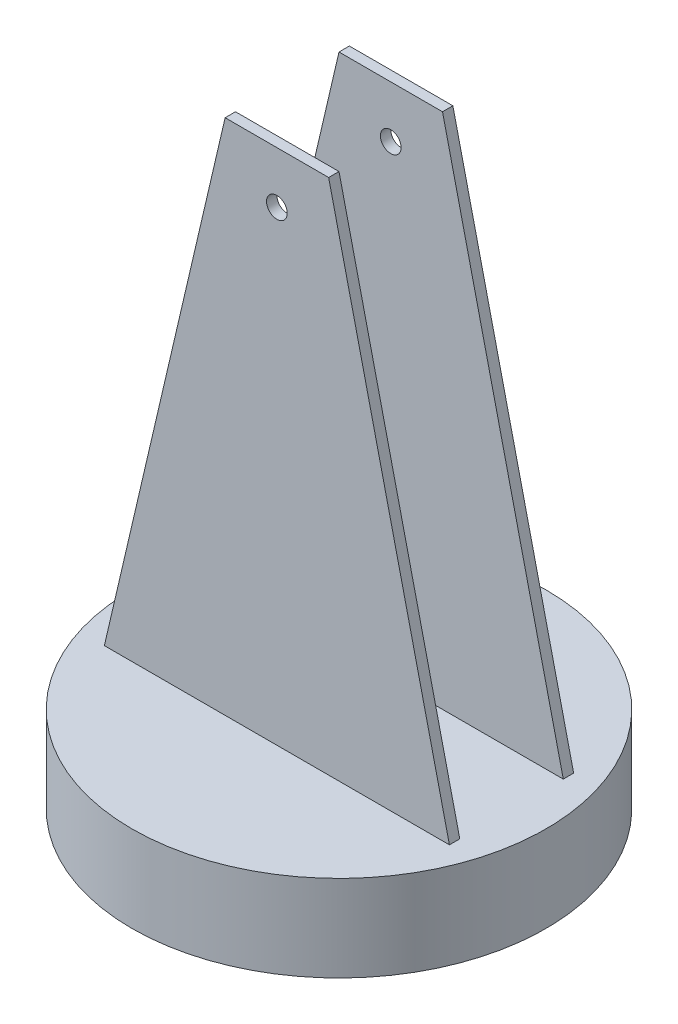
from build123d import *

# Parameters (mm, degrees)
CROQUIS1_R              = 60
SALIENTE_EXTRUIR3_DEPTH = 25
CROQUIS4_W              = 100
CROQUIS4_H              = 3
SALIENTE_EXTRUIR5_DEPTH = 150
CORTAR_EXTRUIR3_DEPTH   = 150
CROQUIS11_R             = 3
CORTAR_EXTRUIR4_DEPTH   = 150


with BuildPart() as part:
    # Croquis1 → Saliente-Extruir3 (new body)
    with BuildSketch(Plane(origin=(0, 0, 0), x_dir=(1, 0, 0), z_dir=(0, 1, 0))):
        Circle(CROQUIS1_R)
    extrude(amount=SALIENTE_EXTRUIR3_DEPTH)

    # Croquis4 → Saliente-Extruir5 (add)
    with BuildSketch(Plane(origin=(0, 25, 0), x_dir=(1, 0, 0), z_dir=(0, 1, 0))):
        with Locations((0, 16.5)):
            Rectangle(CROQUIS4_W, CROQUIS4_H)
        Polygon((0, -15), (50, -15), (50, -18), (-50, -18), (-50, -15), align=None)
    extrude(amount=SALIENTE_EXTRUIR5_DEPTH)

    # Croquis10 → Cortar-Extruir3 (cut)
    with BuildSketch(Plane.XY.offset(18)):
        Polygon((-50, 175), (-15, 175), (-50, 25), align=None)
        Polygon((50, 25), (15, 175), (50, 175), align=None)
    extrude(amount=-CORTAR_EXTRUIR3_DEPTH, mode=Mode.SUBTRACT)

    # Croquis11 → Cortar-Extruir4 (cut)
    with BuildSketch(Plane.XY.offset(18)):
        with Locations((0, 160)):
            Circle(CROQUIS11_R)
    extrude(amount=-CORTAR_EXTRUIR4_DEPTH, mode=Mode.SUBTRACT)


solid = part.part
